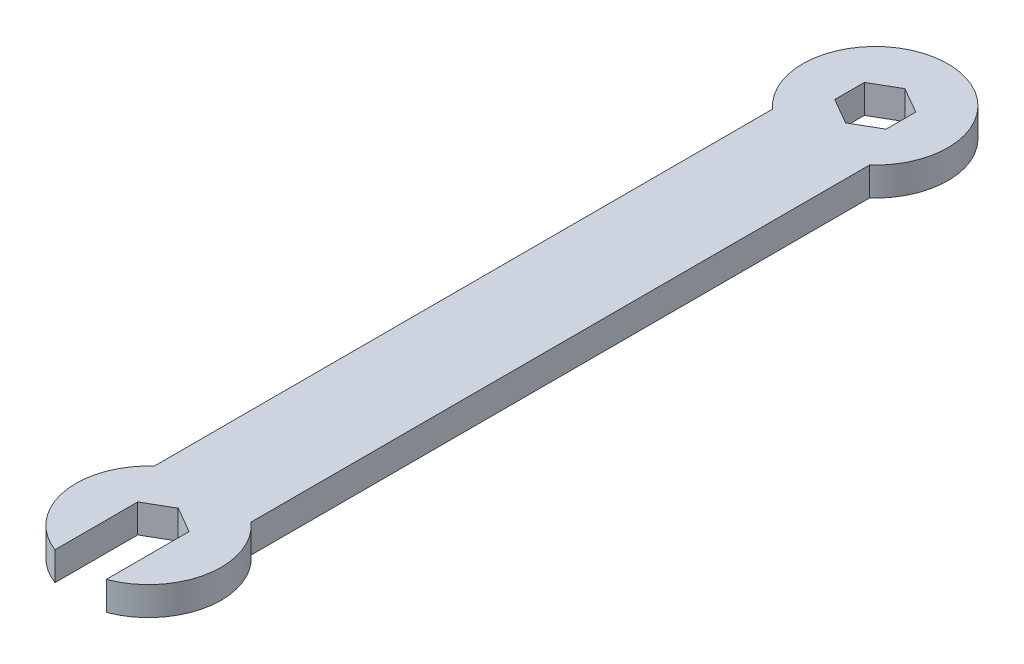
from build123d import *

# Parameters (mm, degrees)
BOSS_EXTRUDE1_DEPTH = 2.95


with BuildPart() as part:
    # Sketch1 → Boss-Extrude1 (new body)
    with BuildSketch(Plane(origin=(0, 0, 0), x_dir=(1, 0, 0), z_dir=(0, 1, 0))):
        with BuildLine():
            Line((5, -75), (5, -69.409830056))
            ThreePointArc((5, -69.409830056), (0, -67.5), (-5, -69.409830056))
            Line((-5, -69.409830056), (-5, -75))
            Line((-5, -75), (-2.65, -75))
            Line((-2.65, -75), (-2.65, -73.470021787))
            Line((-2.65, -73.470021787), (0, -71.940043573))
            Line((0, -71.940043573), (2.65, -73.470021787))
            Line((2.65, -73.470021787), (2.65, -75))
            Line((2.65, -75), (5, -75))
        make_face()
        with BuildLine():
            Line((-5, -75), (-5, -69.409830056))
            ThreePointArc((-5, -69.409830056), (-7.372988698, -76.374422666), (-2.65, -82.016231182))
            Line((-2.65, -82.016231182), (-2.65, -76.529978213))
            Line((-2.65, -76.529978213), (-2.65, -75))
            Line((-2.65, -75), (-5, -75))
        make_face()
        with BuildLine():
            ThreePointArc((7.5, -75), (6.846531969, -71.938137822), (5, -69.409830056))
            Line((5, -69.409830056), (5, -75))
            Line((5, -75), (2.65, -75))
            Line((2.65, -75), (2.65, -76.529978213))
            Line((2.65, -76.529978213), (2.65, -82.016231182))
            ThreePointArc((2.65, -82.016231182), (6.16948134, -79.264680527), (7.5, -75))
        make_face()
        with BuildLine():
            Line((5, -69.409830056), (5, -5.590169944))
            ThreePointArc((5, -5.590169944), (0, -7.5), (-5, -5.590169944))
            Line((-5, -5.590169944), (-5, -69.409830056))
            ThreePointArc((-5, -69.409830056), (0, -67.5), (5, -69.409830056))
        make_face()
        with BuildLine():
            Line((2.65, 1.529978213), (2.65, 0))
            Line((2.65, 0), (5, 0))
            Line((5, 0), (5, -5.590169944))
            ThreePointArc((5, -5.590169944), (6.846531969, -3.061862178), (7.5, 0))
            ThreePointArc((7.5, 0), (-3.061862178, 6.846531969), (-5, -5.590169944))
            Line((-5, -5.590169944), (-5, 0))
            Line((-5, 0), (-2.65, 0))
            Line((-2.65, 0), (-2.65, 1.529978213))
            Line((-2.65, 1.529978213), (0, 3.059956427))
            Line((0, 3.059956427), (2.65, 1.529978213))
        make_face()
        with BuildLine():
            Line((2.65, -1.529978213), (0, -3.059956427))
            Line((0, -3.059956427), (-2.65, -1.529978213))
            Line((-2.65, -1.529978213), (-2.65, 0))
            Line((-2.65, 0), (-5, 0))
            Line((-5, 0), (-5, -5.590169944))
            ThreePointArc((-5, -5.590169944), (0, -7.5), (5, -5.590169944))
            Line((5, -5.590169944), (5, 0))
            Line((5, 0), (2.65, 0))
            Line((2.65, 0), (2.65, -1.529978213))
        make_face()
    extrude(amount=BOSS_EXTRUDE1_DEPTH)


solid = part.part
